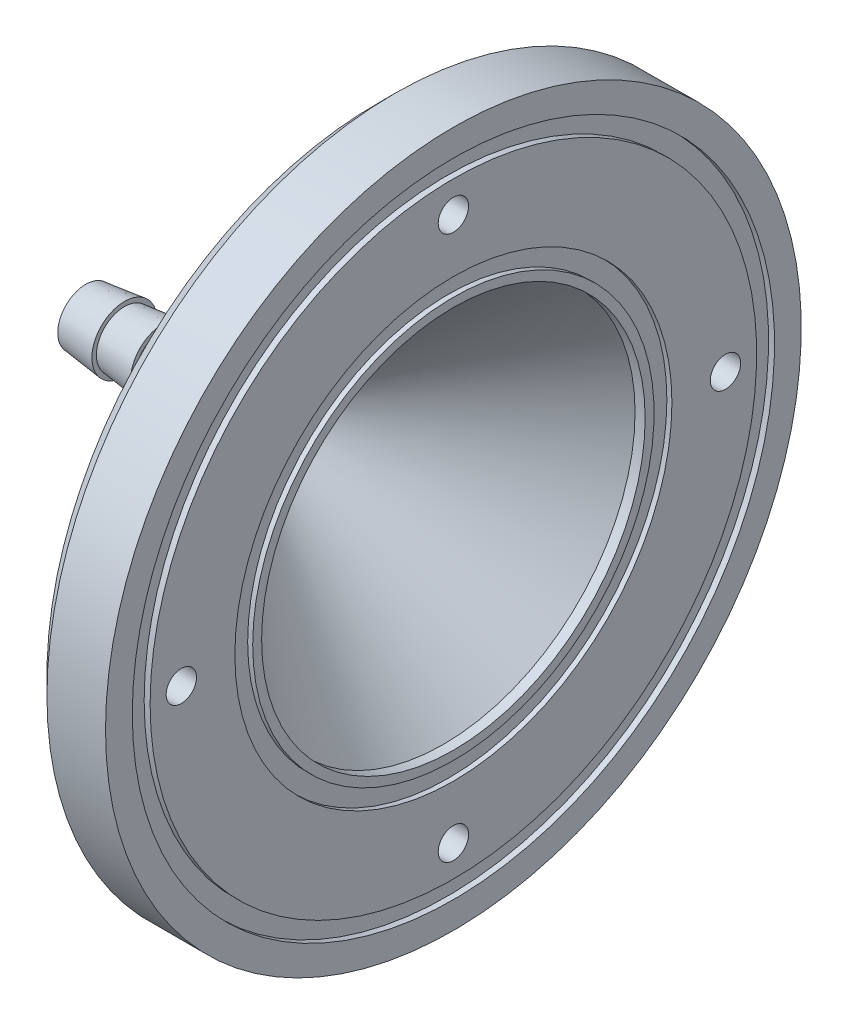
from build123d import *

# Parameters (mm, degrees)
SKETCH1_W                                           = 0.566
SKETCH1_H                                           = 1
CBORE_FOR_M3_HEX_SOCKET_HEAD_CAP_SCREW2_D           = 3.4
CBORE_FOR_M3_HEX_SOCKET_HEAD_CAP_SCREW2_DEPTH       = 8.566
CBORE_FOR_M3_HEX_SOCKET_HEAD_CAP_SCREW2_CBORE_D     = 6.5
CBORE_FOR_M3_HEX_SOCKET_HEAD_CAP_SCREW2_CBORE_DEPTH = 3.4
CBORE_FOR_M3_HEX_SOCKET_HEAD_CAP_SCREW2_TIP         = 1.021463052
CHAMFER1_SIZE                                       = 2


with BuildPart() as part:
    # Sketch1 → Revolve17 (revolve)
    with BuildSketch(Plane.XY):
        Polygon((-14.175209939, 3.15), (-14.175209939, 3.65), (-18.508543272, 3.15), (-18.508543272, 1.9), (0, 1.9), (21.56511535, 21.5), (22.13111535, 21.5), (22.13111535, 22.5), (22.13111535, 24.5), (22.69711535, 24.5), (22.69711535, 34), (22.03011535, 34), (22.03011535, 36), (22.69711535, 36), (22.69711535, 39), (14.13111535, 39), (14.13111535, 21.5), (-5.508543272, 3.65), (-9.841876606, 3.15), (-9.841876606, 3.65), align=None)
        with Locations((22.41411535, 22)):
            Rectangle(SKETCH1_W, SKETCH1_H)
    revolve(axis=Axis((-801.920554309, 0, 0), (1, 0, 0)))

    # CBORE for M3 Hex Socket Head Cap Screw2
    with Locations(Plane.ZY.offset(-14.13111535)):
        with Locations((0, -30.5), (0, 30.5), (30.5, 0), (-30.5, 0)):
            CounterBoreHole(CBORE_FOR_M3_HEX_SOCKET_HEAD_CAP_SCREW2_D / 2, CBORE_FOR_M3_HEX_SOCKET_HEAD_CAP_SCREW2_CBORE_D / 2, CBORE_FOR_M3_HEX_SOCKET_HEAD_CAP_SCREW2_CBORE_DEPTH, depth=CBORE_FOR_M3_HEX_SOCKET_HEAD_CAP_SCREW2_DEPTH)
            with Locations((0, 0, -(CBORE_FOR_M3_HEX_SOCKET_HEAD_CAP_SCREW2_DEPTH + CBORE_FOR_M3_HEX_SOCKET_HEAD_CAP_SCREW2_TIP / 2))):  # 118° drill point
                Cone(0, CBORE_FOR_M3_HEX_SOCKET_HEAD_CAP_SCREW2_D / 2, CBORE_FOR_M3_HEX_SOCKET_HEAD_CAP_SCREW2_TIP, mode=Mode.SUBTRACT)

    # Chamfer1
    chamfer1_edges = [part.edges().sort_by_distance(p)[0] for p in [
        (14.13111535, -39, 0),
    ]]
    chamfer(chamfer1_edges, length=CHAMFER1_SIZE)


solid = part.part
